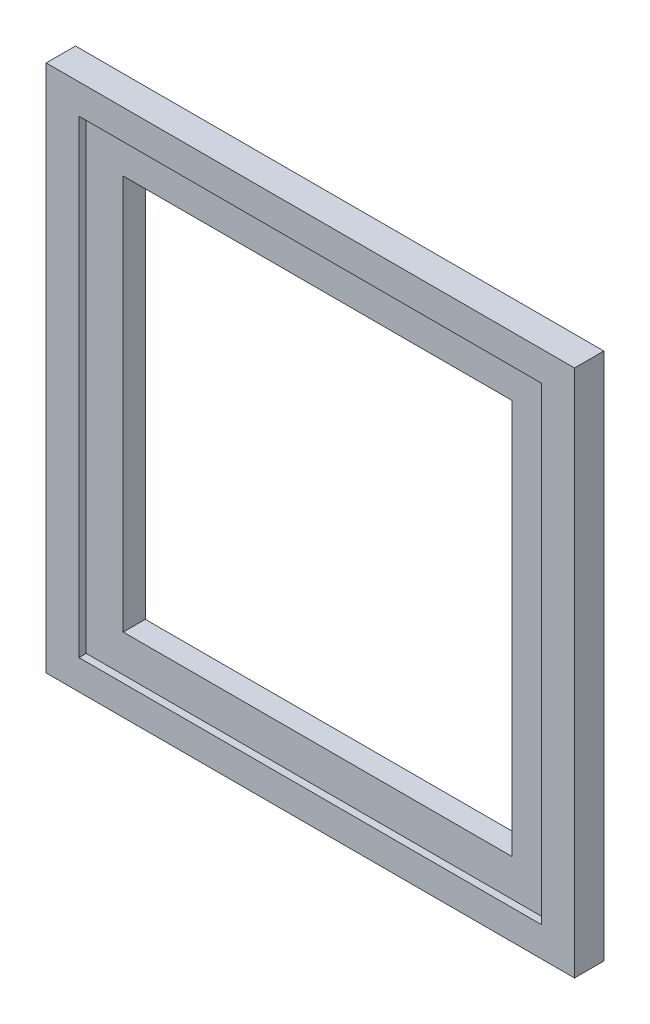
from build123d import *

# Parameters (mm, degrees)
SKETCH1_W               = 114.3
SKETCH1_H               = 114.3
BOSS_EXTRUDE1_DEPTH     = 6.35
SKETCH2_W               = 100.12
SKETCH2_H               = 101.45
CUT_EXTRUDE1_DEPTH      = 1.5748
SKETCH4_W               = 84.12
SKETCH4_H               = 85.45
CUT_EXTRUDE3_DEPTH      = 2.5748
CUT_EXTRUDE3_DEPTH_BACK = 5.7752


with BuildPart() as part:
    # Sketch1 → Boss-Extrude1 (new body)
    with BuildSketch(Plane.XY):
        with Locations((46.081843575, 7.768994413)):
            Rectangle(SKETCH1_W, SKETCH1_H)
    extrude(amount=BOSS_EXTRUDE1_DEPTH)

    # Sketch2 → Cut-Extrude1 (cut)
    with BuildSketch(Plane.XY.offset(6.35)):
        with Locations((46.081843575, 7.768994413)):
            Rectangle(SKETCH2_W, SKETCH2_H)
    extrude(amount=-CUT_EXTRUDE1_DEPTH, mode=Mode.SUBTRACT)

    # Sketch4 → Cut-Extrude3 (cut, two sides)
    with BuildSketch(Plane.XY.offset(4.7752)) as cut_extrude3_sk:
        with Locations((46.081843575, 7.768994413)):
            Rectangle(SKETCH4_W, SKETCH4_H)
    extrude(amount=CUT_EXTRUDE3_DEPTH, mode=Mode.SUBTRACT)
    extrude(cut_extrude3_sk.sketch, amount=-CUT_EXTRUDE3_DEPTH_BACK, mode=Mode.SUBTRACT)


solid = part.part
